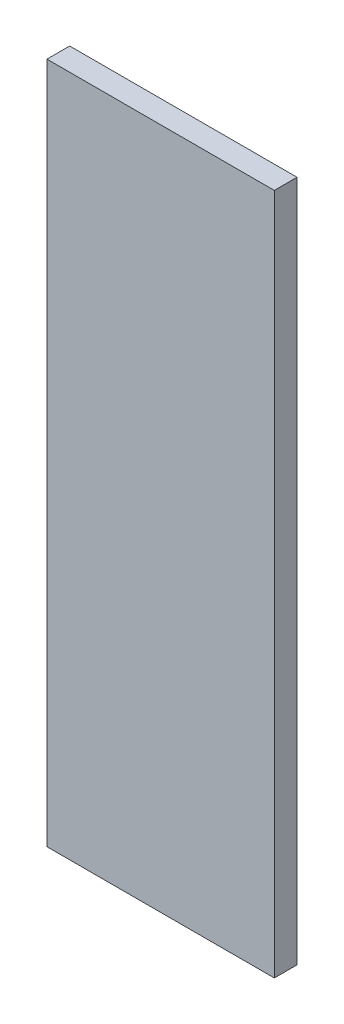
from build123d import *

# Parameters (mm, degrees)
SKETCH1_W           = 63.5
SKETCH1_H           = 190.5
BOSS_EXTRUDE1_DEPTH = 6.35


with BuildPart() as part:
    # Sketch1 → Boss-Extrude1 (new body)
    with BuildSketch(Plane.XY):
        Rectangle(SKETCH1_W, SKETCH1_H)
    extrude(amount=BOSS_EXTRUDE1_DEPTH)


solid = part.part
